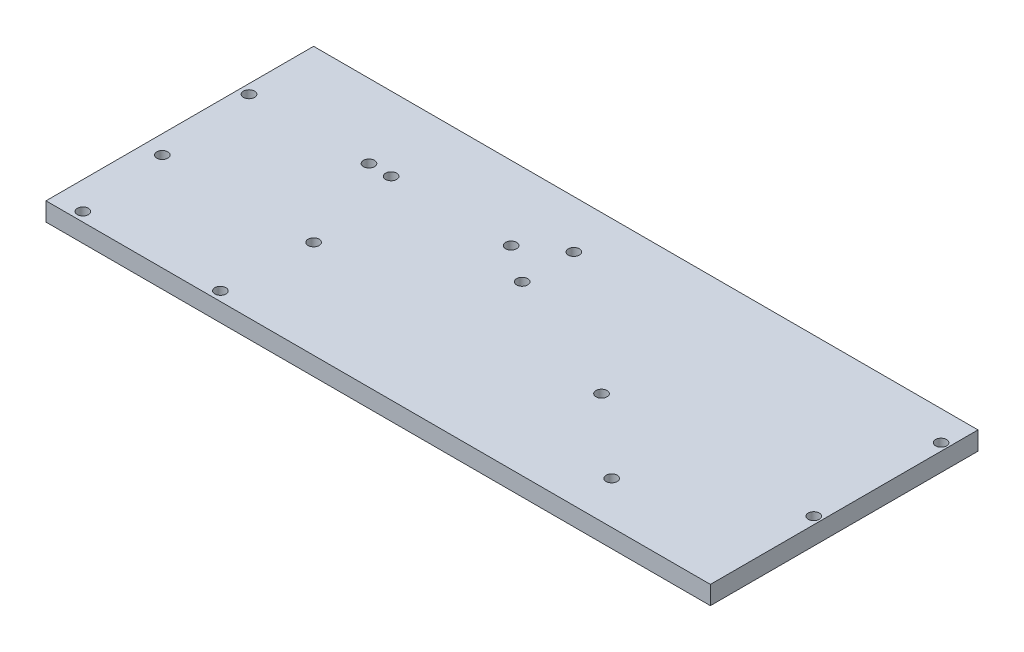
from build123d import *

# Parameters (mm, degrees)
SKETCH1_W           = 360
SKETCH1_H           = 145
SKETCH1_R           = 3
BOSS_EXTRUDE1_DEPTH = 10


with BuildPart() as part:
    # Sketch1 → Boss-Extrude1 (new body)
    with BuildSketch(Plane(origin=(0, 0, 0), x_dir=(1, 0, 0), z_dir=(0, 1, 0))):
        with Locations((180, 72.5)):
            Rectangle(SKETCH1_W, SKETCH1_H)
        with Locations((15, 5)):
            Circle(SKETCH1_R, mode=Mode.SUBTRACT)
        with Locations((10, 53)):
            Circle(SKETCH1_R, mode=Mode.SUBTRACT)
        with Locations((92, 53)):
            Circle(SKETCH1_R, mode=Mode.SUBTRACT)
        with Locations((89.5, 5)):
            Circle(SKETCH1_R, mode=Mode.SUBTRACT)
        with Locations((5, 105)):
            Circle(SKETCH1_R, mode=Mode.SUBTRACT)
        with Locations((70, 105)):
            Circle(SKETCH1_R, mode=Mode.SUBTRACT)
        with Locations((82, 105)):
            Circle(SKETCH1_R, mode=Mode.SUBTRACT)
        with Locations((147, 105)):
            Circle(SKETCH1_R, mode=Mode.SUBTRACT)
        with Locations((356, 60)):
            Circle(SKETCH1_R, mode=Mode.SUBTRACT)
        with Locations((356, 129)):
            Circle(SKETCH1_R, mode=Mode.SUBTRACT)
        with Locations((241, 60)):
            Circle(SKETCH1_R, mode=Mode.SUBTRACT)
        with Locations((283.5, 23)):
            Circle(SKETCH1_R, mode=Mode.SUBTRACT)
        with Locations((167, 91)):
            Circle(SKETCH1_R, mode=Mode.SUBTRACT)
        with Locations((167, 119)):
            Circle(SKETCH1_R, mode=Mode.SUBTRACT)
    extrude(amount=BOSS_EXTRUDE1_DEPTH)


solid = part.part
